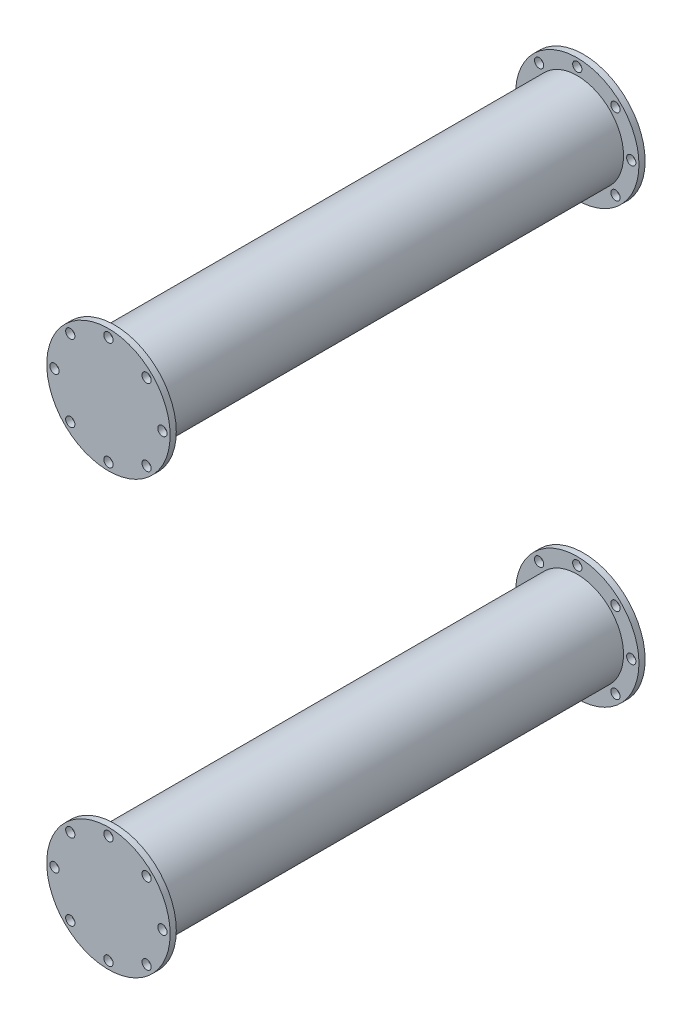
from build123d import *

# Parameters (mm, degrees)
SKETCH1_R             = 20
SKETCH1_R_2           = 1.5
BOSS_EXTRUDE1_DEPTH   = 2
BOSS_EXTRUDE1_2_DEPTH = 2
SKETCH2_R             = 15
BOSS_EXTRUDE2_DEPTH   = 150
SKETCH4_R             = 20
SKETCH4_R_2           = 1.5
BOSS_EXTRUDE3_DEPTH   = 2


with BuildPart() as part:
    # Sketch1 → Boss-Extrude1 (new body)
    with BuildSketch(Plane.XY):
        with Locations((0, 170)):
            Circle(SKETCH1_R)
        with Locations((0, 187.5)):
            Circle(SKETCH1_R_2, mode=Mode.SUBTRACT)
        with Locations((12.374368671, 182.374368671)):
            Circle(SKETCH1_R_2, mode=Mode.SUBTRACT)
        with Locations((17.5, 170)):
            Circle(SKETCH1_R_2, mode=Mode.SUBTRACT)
        with Locations((12.374368671, 157.625631329)):
            Circle(SKETCH1_R_2, mode=Mode.SUBTRACT)
        with Locations((0, 152.5)):
            Circle(SKETCH1_R_2, mode=Mode.SUBTRACT)
        with Locations((-12.374368671, 157.625631329)):
            Circle(SKETCH1_R_2, mode=Mode.SUBTRACT)
        with Locations((-17.5, 170)):
            Circle(SKETCH1_R_2, mode=Mode.SUBTRACT)
        with Locations((-12.374368671, 182.374368671)):
            Circle(SKETCH1_R_2, mode=Mode.SUBTRACT)
    extrude(amount=BOSS_EXTRUDE1_DEPTH)



with BuildPart() as body_2:
    # Sketch1 → Boss-Extrude1 2 (new body)
    with BuildSketch(Plane.XY):
        with Locations((0, 30)):
            Circle(SKETCH1_R)
        with Locations((0, 47.5)):
            Circle(SKETCH1_R_2, mode=Mode.SUBTRACT)
        with Locations((12.374368671, 42.374368671)):
            Circle(SKETCH1_R_2, mode=Mode.SUBTRACT)
        with Locations((17.5, 30)):
            Circle(SKETCH1_R_2, mode=Mode.SUBTRACT)
        with Locations((12.374368671, 17.625631329)):
            Circle(SKETCH1_R_2, mode=Mode.SUBTRACT)
        with Locations((0, 12.5)):
            Circle(SKETCH1_R_2, mode=Mode.SUBTRACT)
        with Locations((-12.374368671, 17.625631329)):
            Circle(SKETCH1_R_2, mode=Mode.SUBTRACT)
        with Locations((-17.5, 30)):
            Circle(SKETCH1_R_2, mode=Mode.SUBTRACT)
        with Locations((-12.374368671, 42.374368671)):
            Circle(SKETCH1_R_2, mode=Mode.SUBTRACT)
    extrude(amount=BOSS_EXTRUDE1_2_DEPTH)


with BuildPart() as part_1:
    add(part.part)

    add(body_2.part)  # Boss-Extrude2 merges body 2
    # Sketch2 → Boss-Extrude2 (add)
    with BuildSketch(Plane.XY.offset(2)):
        with Locations((0, 170)):
            Circle(SKETCH2_R)
        with Locations((0, 30)):
            Circle(SKETCH2_R)
    extrude(amount=BOSS_EXTRUDE2_DEPTH)

    # Sketch4 → Boss-Extrude3 (add)
    with BuildSketch(Plane.XY.offset(152)):
        with Locations((0, 170)):
            Circle(SKETCH4_R)
        with Locations((0, 187.5)):
            Circle(SKETCH4_R_2, mode=Mode.SUBTRACT)
        with Locations((12.374368671, 182.374368671)):
            Circle(SKETCH4_R_2, mode=Mode.SUBTRACT)
        with Locations((17.5, 170)):
            Circle(SKETCH4_R_2, mode=Mode.SUBTRACT)
        with Locations((12.374368671, 157.625631329)):
            Circle(SKETCH4_R_2, mode=Mode.SUBTRACT)
        with Locations((0, 152.5)):
            Circle(SKETCH4_R_2, mode=Mode.SUBTRACT)
        with Locations((-12.374368671, 157.625631329)):
            Circle(SKETCH4_R_2, mode=Mode.SUBTRACT)
        with Locations((-17.5, 170)):
            Circle(SKETCH4_R_2, mode=Mode.SUBTRACT)
        with Locations((-12.374368671, 182.374368671)):
            Circle(SKETCH4_R_2, mode=Mode.SUBTRACT)
        with Locations((0, 30)):
            Circle(SKETCH4_R)
        with Locations((0, 47.5)):
            Circle(SKETCH4_R_2, mode=Mode.SUBTRACT)
        with Locations((12.374368671, 42.374368671)):
            Circle(SKETCH4_R_2, mode=Mode.SUBTRACT)
        with Locations((17.5, 30)):
            Circle(SKETCH4_R_2, mode=Mode.SUBTRACT)
        with Locations((12.374368671, 17.625631329)):
            Circle(SKETCH4_R_2, mode=Mode.SUBTRACT)
        with Locations((0, 12.5)):
            Circle(SKETCH4_R_2, mode=Mode.SUBTRACT)
        with Locations((-12.374368671, 17.625631329)):
            Circle(SKETCH4_R_2, mode=Mode.SUBTRACT)
        with Locations((-17.5, 30)):
            Circle(SKETCH4_R_2, mode=Mode.SUBTRACT)
        with Locations((-12.374368671, 42.374368671)):
            Circle(SKETCH4_R_2, mode=Mode.SUBTRACT)
    extrude(amount=BOSS_EXTRUDE3_DEPTH)


solid = part_1.part
